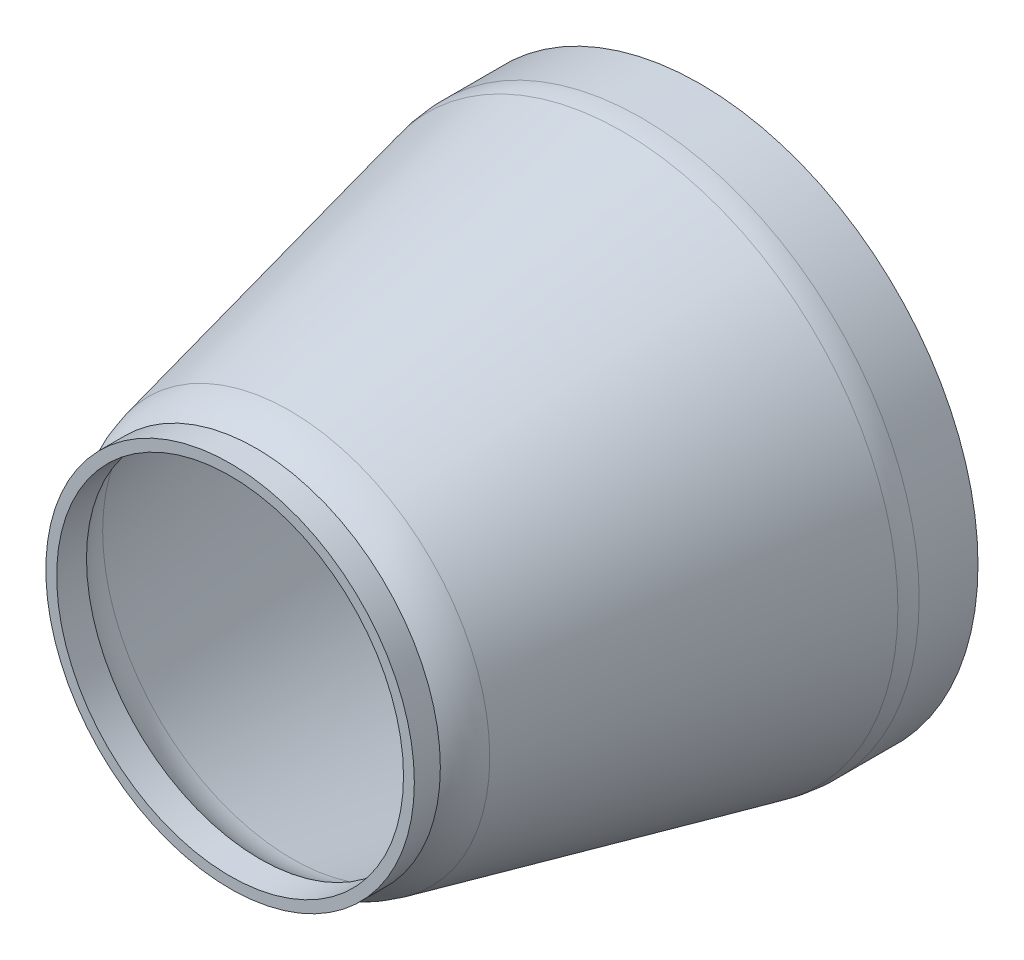
from build123d import *

# Parameters (mm, degrees)
FILLET1_R = 20
SHELL1_T  = -2.5


with BuildPart() as part:
    # Sketch2 → Revolve1 (revolve)
    with BuildSketch(Plane(origin=(0, 0, 0), x_dir=(1, 0, 0), z_dir=(0, 1, 0))):
        with BuildLine():
            Line((0, -108.5), (0, -6))
            Line((0, -6), (47.816178594, -6))
            Line((47.816178594, -6), (50, 0))
            Line((50, 0), (64, 0))
            Line((64, 0), (64, -15.8))
            Line((64, -15.8), (46.137243112, -94.742026455))
            ThreePointArc((46.137243112, -94.742026455), (44.738953709, -98.818081472), (42.5, -102.5))
            Line((42.5, -102.5), (42.5, -108.5))
            Line((42.5, -108.5), (0, -108.5))
        make_face()
    revolve(axis=Axis((0, 0, 108.5), (0, 0, -1)))

    # Fillet1
    fillet1_edges = [part.edges().sort_by_distance(p)[0] for p in [
        (-64, 0, 15.8),
    ]]
    fillet(fillet1_edges, radius=FILLET1_R)

    # Shell1
    shell1_openings = [part.faces().sort_by_distance(p)[0] for p in [
        (0, 0, 108.5),
    ]]
    offset(amount=SHELL1_T, openings=shell1_openings, kind=Kind.INTERSECTION)


solid = part.part
